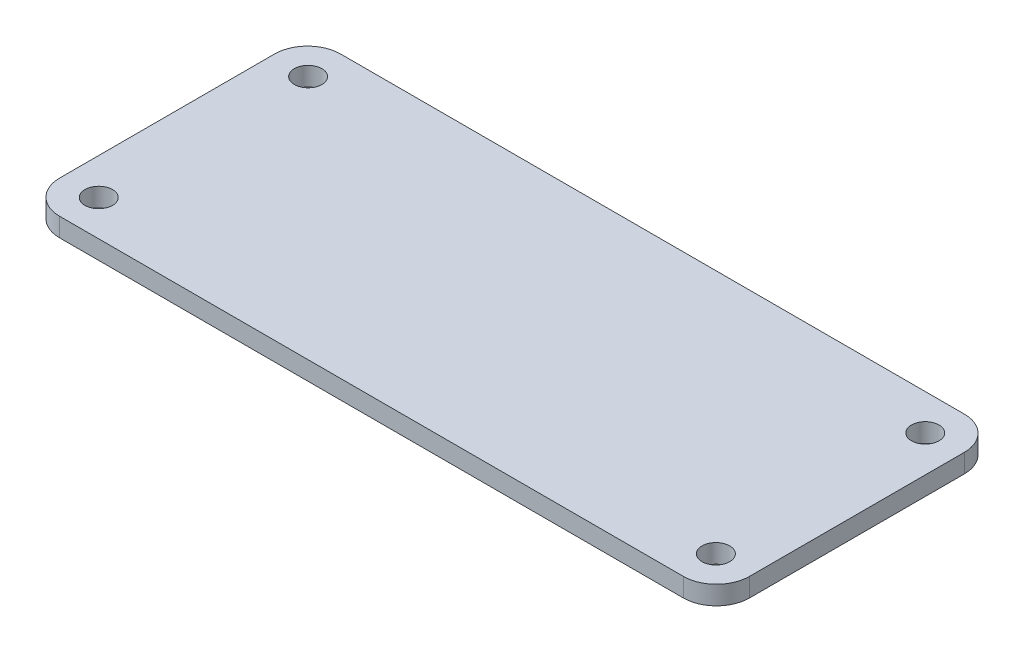
from build123d import *

# Parameters (mm, degrees)
SKETCH1_W           = 62.6
SKETCH1_H           = 25.5
SKETCH1_R           = 1.25
BOSS_EXTRUDE1_DEPTH = 1.7
FILLET1_R           = 3


with BuildPart() as part:
    # Sketch1 → Boss-Extrude1 (new body)
    with BuildSketch(Plane(origin=(0, 0, 0), x_dir=(1, 0, 0), z_dir=(0, 1, 0))):
        Rectangle(SKETCH1_W, SKETCH1_H)
        with Locations((-28, 9.5)):
            Circle(SKETCH1_R, mode=Mode.SUBTRACT)
        with Locations((28, 9.5)):
            Circle(SKETCH1_R, mode=Mode.SUBTRACT)
        with Locations((28, -9.5)):
            Circle(SKETCH1_R, mode=Mode.SUBTRACT)
        with Locations((-28, -9.5)):
            Circle(SKETCH1_R, mode=Mode.SUBTRACT)
    extrude(amount=BOSS_EXTRUDE1_DEPTH)

    # Fillet1
    fillet1_edges = [part.edges().sort_by_distance(p)[0] for p in [
        (31.3, 0.85, -12.75),
        (31.3, 0.85, 12.75),
        (-31.3, 0.85, -12.75),
        (-31.3, 0.85, 12.75),
    ]]
    fillet(fillet1_edges, radius=FILLET1_R)


solid = part.part
